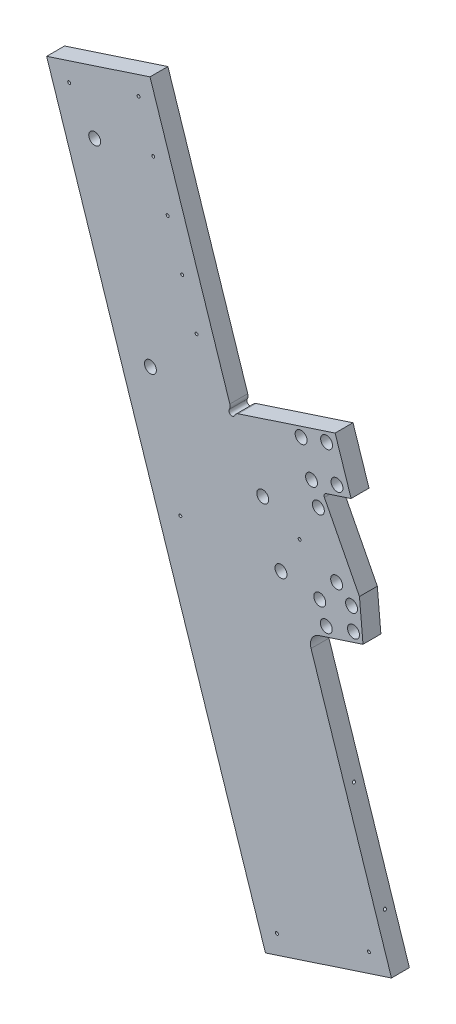
from build123d import *

# Parameters (mm, degrees)
BOSS_EXTRUDE1_DEPTH        = 19.05
BOSS_EXTRUDE2_DEPTH        = 19.05
FILLET1_R                  = 3.175
FILLET2_R                  = 12.7
SKETCH47_R                 = 3.175
CUT_EXTRUDE1_DEPTH         = 1
CUT_EXTRUDE1_DEPTH_BACK    = 20.05
FILLET4_R                  = 6.35
F_1_2_0_5_DIAMETER_HOLE1_D = 12.7
HOLE7_D                    = 3.175
HOLE7_DEPTH                = 38.1
HOLE7_CSINK_D              = 10.16
HOLE7_CSINK_ANGLE          = 82
HOLE7_TIP                  = 0.953866233
HOLE10_D                   = 3.175
HOLE10_DEPTH               = 57.15
HOLE10_CSINK_D             = 10.16
HOLE10_CSINK_ANGLE         = 82
HOLE10_TIP                 = 0.953866233
HOLE13_D                   = 3.175
HOLE13_DEPTH               = 31.75
HOLE13_CSINK_D             = 10.16
HOLE13_CSINK_ANGLE         = 82
HOLE13_TIP                 = 0.953866233


with BuildPart() as part:
    # Sketch1 → Boss-Extrude1 (new body)
    with BuildSketch(Plane.XY):
        Polygon((-247.274665566, 82.142339986), (-381.523973725, 38.103910865), (-614.640105377, 748.748682245), (-504.525442447, 784.870110692), (-417.251419261, 518.818903446), (-393.116774032, 526.735904121), align=None)
    extrude(amount=-BOSS_EXTRUDE1_DEPTH)

    # Sketch2 → Boss-Extrude2 (add, through all)
    with BuildSketch(Plane.XY):
        Polygon((-393.116774032, 526.735904121), (-336.901176267, 355.36500697), (-277.604402796, 374.816405204), (-281.415155825, 417.005352091), (-320.44916939, 493.083731154), (-290.280862854, 502.979981998), (-307.307307279, 554.884385267), align=None)
    extrude(amount=-BOSS_EXTRUDE2_DEPTH)

    # Fillet1
    fillet1_edges = [part.edges().sort_by_distance(p)[0] for p in [
        (-320.44916939, 493.083731154, -9.525),
    ]]
    fillet(fillet1_edges, radius=FILLET1_R)

    # Fillet2
    fillet2_edges = [part.edges().sort_by_distance(p)[0] for p in [
        (-336.901176267, 355.36500697, -9.525),
    ]]
    fillet(fillet2_edges, radius=FILLET2_R)

    # Sketch47 → Cut-Extrude1 (cut, two sides)
    with BuildSketch(Plane(origin=(0, 0, -19.05), x_dir=(-1, 0, 0), z_dir=(0, 0, -1))) as cut_extrude1_sk:
        with Locations((417.251419261, 518.818903446)):
            Circle(SKETCH47_R)
    extrude(amount=CUT_EXTRUDE1_DEPTH, mode=Mode.SUBTRACT)
    extrude(cut_extrude1_sk.sketch, amount=-CUT_EXTRUDE1_DEPTH_BACK, mode=Mode.SUBTRACT)

    # Fillet4
    fillet4_edges = [part.edges().sort_by_distance(p)[0] for p in [
        (-418.241044345, 521.8357341, -9.525),
        (-414.234588607, 519.80852853, -9.525),
    ]]
    fillet(fillet4_edges, radius=FILLET4_R)

    # 1/2 (0.5) Diameter Hole1 (through all)
    with Locations(Plane.XY):
        with Locations((-563.45033927, 698.544682362), (-504.072834209, 517.534843147), (-316.771364786, 371.99266929), (-323.698740376, 393.110483865), (-289.824308357, 404.222472403), (-287.772364418, 381.505347156), (-305.715281117, 417.978415836), (-364.985283482, 398.535799453), (-384.427899865, 457.805801818), (-325.157897499, 477.248418201), (-332.468536604, 499.165347862), (-305.317060721, 508.071973621), (-316.40575464, 541.875392969), (-343.557230523, 532.968767209)):
            Hole(F_1_2_0_5_DIAMETER_HOLE1_D / 2)

    # Hole7
    with Locations(Plane(origin=(313.774034821, -375.700785936, 19.05), x_dir=(0.997756458, -0.066948111, 0), z_dir=(0, 0, 1))):
        with Locations((-710.914924699, 391.126528253), (-615.24080496, 429.781381762), (-711.83598555, 767.659094962), (-835.937309391, 717.51890547), (-904.68821492, 1078.38439498), (-976.811864753, 1049.244548945)):
            CounterSinkHole(HOLE7_D / 2, HOLE7_CSINK_D / 2, depth=HOLE7_DEPTH, counter_sink_angle=HOLE7_CSINK_ANGLE)
            with Locations((0, 0, -(HOLE7_DEPTH + HOLE7_TIP / 2))):  # 118° drill point
                Cone(0, HOLE7_D / 2, HOLE7_TIP, mode=Mode.SUBTRACT)

    # Hole10
    with Locations(Plane(origin=(313.774034821, -375.700785936, -57.15), x_dir=(-0.997756458, 0.066948111, 0), z_dir=(0, 0, -1))):
        with Locations((848.944412528, 940.413642522), (885.927448463, 1031.949868564), (867.435930496, 986.181755543), (830.452894561, 894.645529501)):
            CounterSinkHole(HOLE10_D / 2, HOLE10_CSINK_D / 2, depth=HOLE10_DEPTH, counter_sink_angle=HOLE10_CSINK_ANGLE)
            with Locations((0, 0, -(HOLE10_DEPTH + HOLE10_TIP / 2))):  # 118° drill point
                Cone(0, HOLE10_D / 2, HOLE10_TIP, mode=Mode.SUBTRACT)

    # Hole13
    with Locations(Plane(origin=(-45.102820315, -493.424841017, 52.974999997), x_dir=(0, 0, -1), z_dir=(0.950182883, 0.31169294, 0))):
        with Locations((174.999999994, 685.961004241), (174.999999994, 549.837259632), (174.999999994, 413.713515022), (81.549999997, 779.649723129), (81.549999997, 652.344645962), (62.499999997, 662.953402392), (62.499999997, 769.040966698), (-62.499999997, 769.040966698), (-62.499999997, 662.953402392), (-81.549999997, 652.344645962), (-81.549999997, 779.649723129), (-174.999999994, 413.713515022), (-174.999999994, 549.837259632), (-174.999999994, 685.961004241), (-82.737499997, 600.384620239), (0, 600.384620239), (82.737499997, 600.384620239), (0, 376.737770337), (-82.737499997, 376.737770337), (82.737499997, 376.737770337)):
            CounterSinkHole(HOLE13_D / 2, HOLE13_CSINK_D / 2, depth=HOLE13_DEPTH, counter_sink_angle=HOLE13_CSINK_ANGLE)
            with Locations((0, 0, -(HOLE13_DEPTH + HOLE13_TIP / 2))):  # 118° drill point
                Cone(0, HOLE13_D / 2, HOLE13_TIP, mode=Mode.SUBTRACT)


solid = part.part
